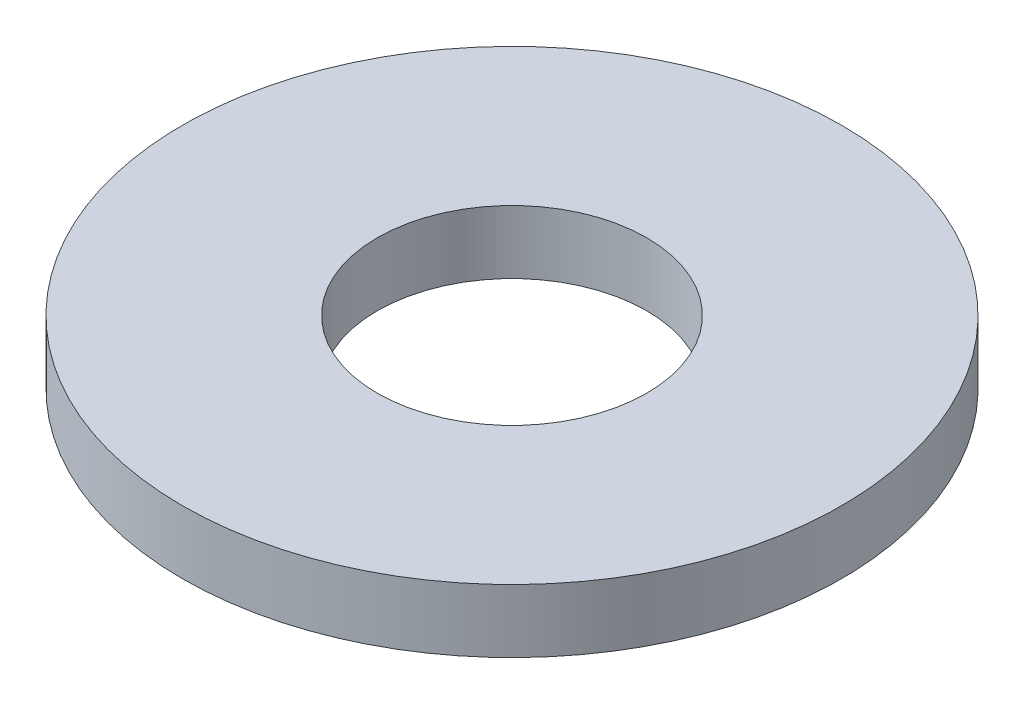
from build123d import *

# Parameters (mm, degrees)
SKETCH1_R           = 17.4625
BOSS_EXTRUDE1_DEPTH = 3.3528
SKETCH5_R           = 7.1374
CUT_EXTRUDE1_DEPTH  = 4.3528


with BuildPart() as part:
    # Sketch1 → Boss-Extrude1 (new body)
    with BuildSketch(Plane(origin=(0, 0, 0), x_dir=(1, 0, 0), z_dir=(0, 1, 0))):
        Circle(SKETCH1_R)
    extrude(amount=BOSS_EXTRUDE1_DEPTH)

    # Sketch5 → Cut-Extrude1 (cut, through all)
    with BuildSketch(Plane(origin=(0, 3.3528, 0), x_dir=(-1, 0, 0), z_dir=(0, 1, 0))):
        Circle(SKETCH5_R)
    extrude(amount=-CUT_EXTRUDE1_DEPTH, mode=Mode.SUBTRACT)


solid = part.part
